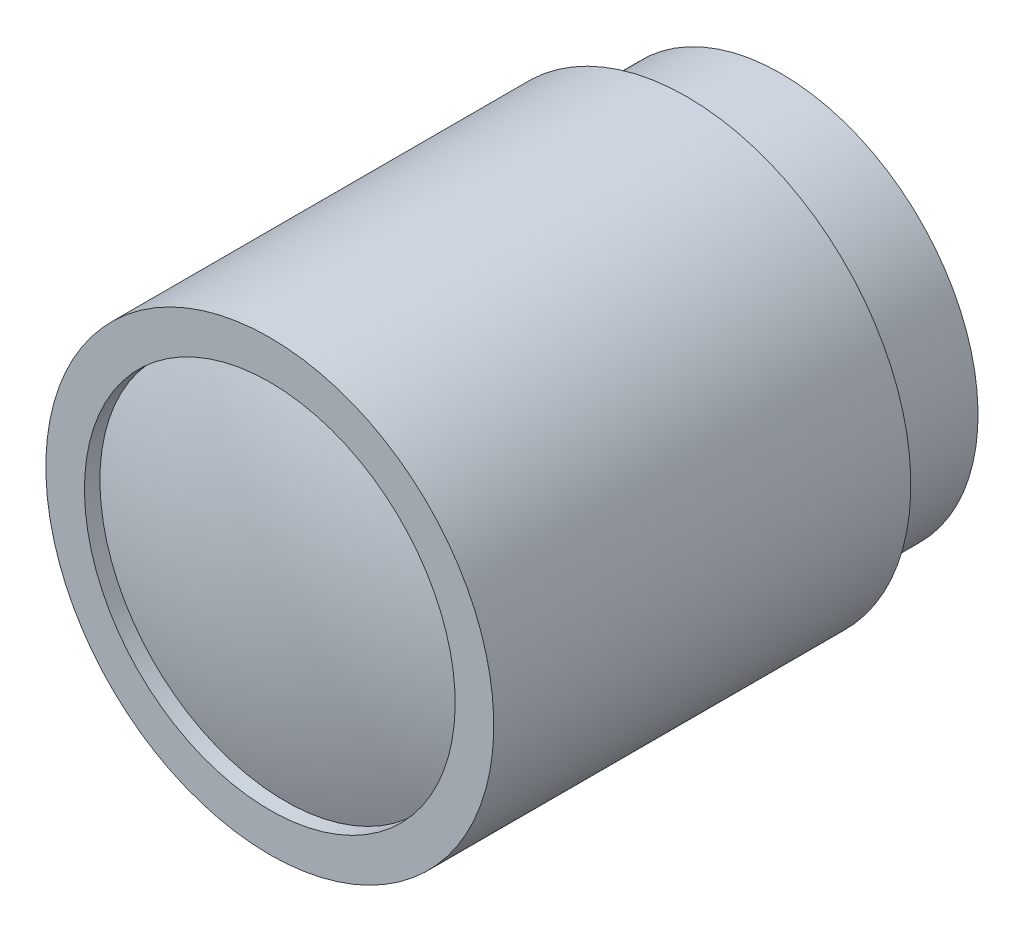
from build123d import *


with BuildPart() as part:
    # Sketch1 → Revolve1 (revolve)
    with BuildSketch(Plane(origin=(0, 0, 0), x_dir=(0, 0, -1), z_dir=(1, 0, 0))):
        with BuildLine():
            Line((-15, 14), (-15, 12))
            Line((-15, 12), (-14, 12))
            ThreePointArc((-14, 12), (-15.496575182, 6.08276253), (-16, 0))
            Line((-16, 0), (18.1, 0))
            Line((18.1, 0), (18.1, 12.75))
            Line((18.1, 12.75), (12, 12.75))
            Line((12, 12.75), (12, 14.5))
            Line((12, 14.5), (-15, 14.5))
            Line((-15, 14.5), (-15, 14))
        make_face()
    revolve(axis=Axis((0, 0, -18.1), (0, 0, 1)))


solid = part.part
